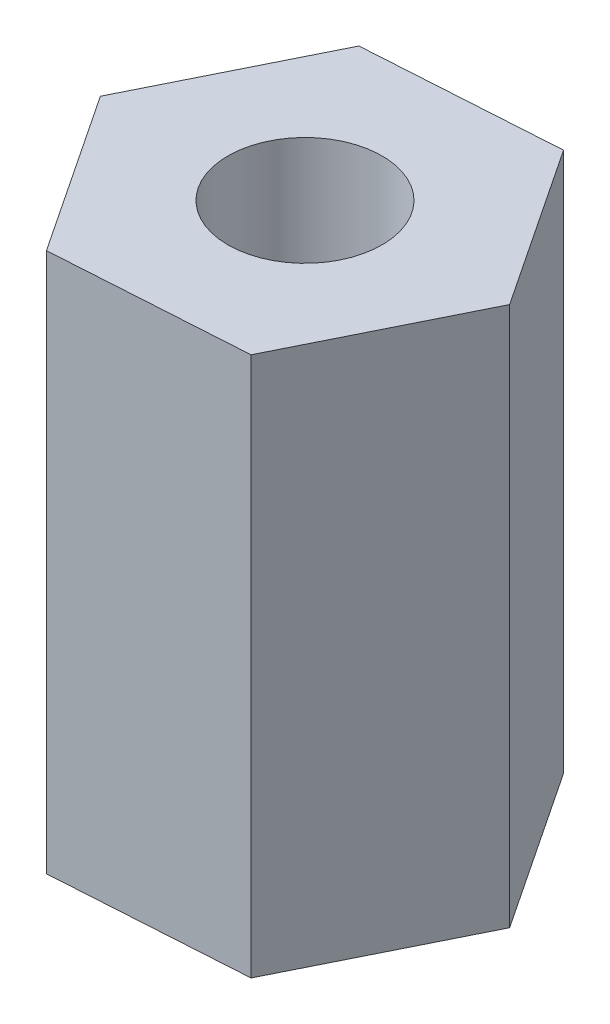
from build123d import *

# Parameters (mm, degrees)
EXTRUDE_1_DEPTH     = 21
SKETCH_2_R          = 3
CUT_EXTRUDE_1_DEPTH = 22


with BuildPart() as part:
    # Эскиз1 → Бобышка-Вытянуть1 (new body)
    with BuildSketch(Plane(origin=(0, 0, 0), x_dir=(1, 0, 0), z_dir=(0, 1, 0))):
        Polygon((-3.337225394, -6.722816374), (4.153517068, -6.251530157), (7.490742462, 0.471286217), (3.337225394, 6.722816374), (-4.153517068, 6.251530157), (-7.490742462, -0.471286217), align=None)
    extrude(amount=EXTRUDE_1_DEPTH)

    # Эскиз2 → Вырез-Вытянуть1 (cut, through all)
    with BuildSketch(Plane(origin=(0, 21, 0), x_dir=(1, 0, 0), z_dir=(0, 1, 0))):
        Circle(SKETCH_2_R)
    extrude(amount=-CUT_EXTRUDE_1_DEPTH, mode=Mode.SUBTRACT)


solid = part.part
